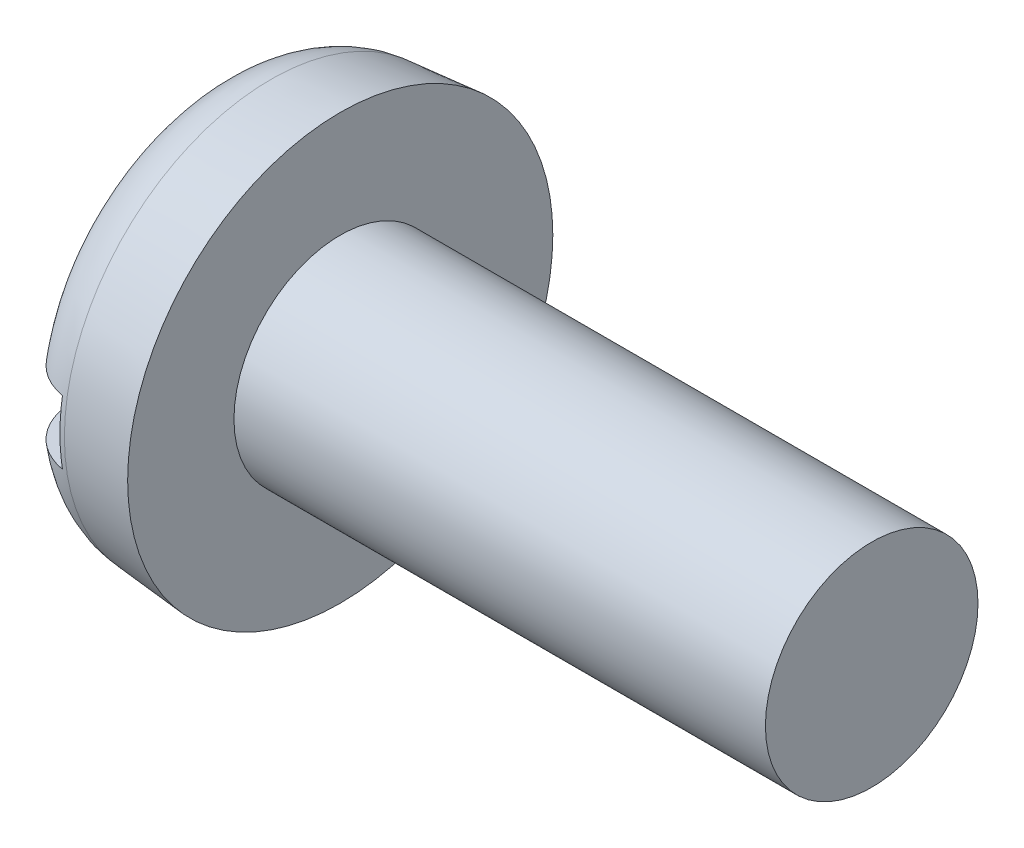
from build123d import *

# Parameters (mm, degrees)
FILLET2_R  = 1.2
SKETCH2_W  = 8
SKETCH2_H  = 1.2
SLOT_DEPTH = 1


with BuildPart() as part:
    # BodySke → Base-Revolve (revolve)
    with BuildSketch(Plane.XY, mode=Mode.PRIVATE) as base_revolve_sk:
        Polygon((2.4, 2), (2.4, 4), (0, 3.790027208), (0, 0), (12.4, 0), (12.4, 2), align=None)
    revolve(base_revolve_sk.sketch.rotate(Axis((-25.4, 0, 0), (1, 0, 0)), 90), axis=Axis((-25.4, 0, 0), (1, 0, 0)))  # turned: the seam where the file's is

    # Fillet2
    fillet2_edges = [part.edges().sort_by_distance(p)[0] for p in [
        (0, 0, -3.790027208),
    ]]
    fillet(fillet2_edges, radius=FILLET2_R)

    # Sketch2 → Slot (cut)
    with BuildSketch(Plane(origin=(0, 0, 0), x_dir=(0, 0, -1), z_dir=(1, 0, 0))):
        Rectangle(SKETCH2_W, SKETCH2_H)
    extrude(amount=SLOT_DEPTH, mode=Mode.SUBTRACT)


solid = part.part
